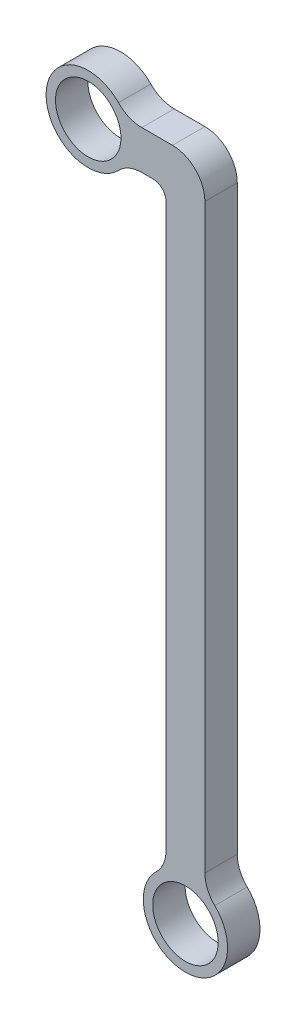
from build123d import *

# Parameters (mm, degrees)
ESQUISSE1_R        = 6.4135
BOSS_EXTRU_1_DEPTH = 6.35


with BuildPart() as part:
    # Esquisse1 → Boss.-Extru.1 (new body)
    with BuildSketch(Plane(origin=(154.130652136, 0, 0), x_dir=(1, 0, 0), z_dir=(0, 0, 1))):
        with BuildLine():
            Line((-138.890652136, -6.35), (-138.890652136, -116.508078107))
            ThreePointArc((-138.890652136, -116.508078107), (-139.393732658, -118.985179762), (-140.823260832, -121.069783278))
            ThreePointArc((-140.823260832, -121.069783278), (-135.080652136, -135.255), (-129.338043441, -121.069783278))
            ThreePointArc((-129.338043441, -121.069783278), (-130.767571615, -118.985179762), (-131.270652136, -116.508078107))
            Line((-131.270652136, -116.508078107), (-131.270652136, -2.54))
            ThreePointArc((-131.270652136, -2.54), (-133.130524076, 1.950128061), (-137.620652136, 3.81))
            Line((-137.620652136, 3.81), (-143.638730244, 3.81))
            ThreePointArc((-143.638730244, 3.81), (-146.115831899, 4.313080521), (-148.200435415, 5.742608696))
            ThreePointArc((-148.200435415, 5.742608696), (-162.385652136, 0), (-148.200435415, -5.742608696))
            ThreePointArc((-148.200435415, -5.742608696), (-146.115831899, -4.313080521), (-143.638730244, -3.81))
            Line((-143.638730244, -3.81), (-141.430652136, -3.81))
            ThreePointArc((-141.430652136, -3.81), (-139.634600912, -4.553948776), (-138.890652136, -6.35))
        make_face()
        with Locations((-135.080652136, -127)):
            Circle(ESQUISSE1_R, mode=Mode.SUBTRACT)
        with Locations((-154.130652136, 0)):
            Circle(ESQUISSE1_R, mode=Mode.SUBTRACT)
    extrude(amount=BOSS_EXTRU_1_DEPTH)


solid = part.part
